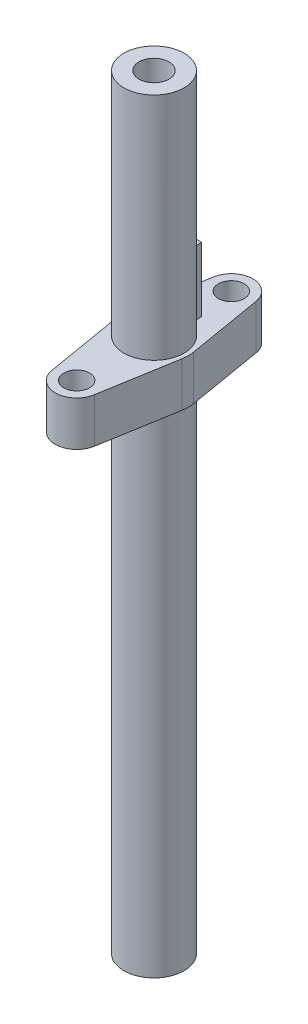
from build123d import *

# Parameters (mm, degrees)
SKETCH1_R           = 3.5
BOSS_EXTRUDE1_DEPTH = 87.927
SKETCH2_R           = 1.75
CUT_EXTRUDE1_DEPTH  = 8.9
CUT_EXTRUDE2_START  = -87.927
SKETCH2_2_R         = 1.75
CUT_EXTRUDE2_DEPTH  = 8.9
CUT_EXTRUDE3_REACH  = 9
SKETCH3_R           = 1.75
BOSS_EXTRUDE2_DEPTH = 7.5
SKETCH5_R           = 1.5
SKETCH5_R_2         = 3.5
BOSS_EXTRUDE3_DEPTH = 5.2
SKETCH6_R           = 3.5
SKETCH6_R_2         = 1.75
BOSS_EXTRUDE5_DEPTH = 1.1
SKETCH7_R           = 1.75
BOSS_EXTRUDE6_DEPTH = 0.4
SKETCH8_R           = 1.75
BOSS_EXTRUDE7_DEPTH = 1.473


with BuildPart() as part:
    # Sketch1 → Boss-Extrude1 (new body)
    with BuildSketch(Plane(origin=(0, 0, 0), x_dir=(1, 0, 0), z_dir=(0, 1, 0))):
        Circle(SKETCH1_R)
    extrude(amount=BOSS_EXTRUDE1_DEPTH)

    # Sketch2 → Cut-Extrude1 (cut)
    with BuildSketch(Plane.XZ):
        Circle(SKETCH2_R)
    extrude(amount=-CUT_EXTRUDE1_DEPTH, mode=Mode.SUBTRACT)

    # Sketch2_2 → Cut-Extrude2 (cut)
    with BuildSketch(Plane.XZ.offset(CUT_EXTRUDE2_START)):
        Circle(SKETCH2_2_R)
    extrude(amount=CUT_EXTRUDE2_DEPTH, mode=Mode.SUBTRACT)

    # Sketch3 → Cut-Extrude3 (cut, up to next)
    with BuildSketch(Plane.ZY.offset(3.5), mode=Mode.PRIVATE) as cut_extrude3_sk1:
        with Locations((0, 4.677)):
            Circle(SKETCH3_R)
    cut_extrude3_tool1 = extrude(cut_extrude3_sk1.sketch, amount=-CUT_EXTRUDE3_REACH, mode=Mode.PRIVATE) & part.part
    add(cut_extrude3_tool1.solids().sort_by_distance((-3.5, 4.677, 0))[0], mode=Mode.SUBTRACT)
    # Sketch3 → Cut-Extrude3 (cut, up to next)
    with BuildSketch(Plane.ZY.offset(3.5), mode=Mode.PRIVATE) as cut_extrude3_sk2:
        with Locations((0, 82.177)):
            Circle(SKETCH3_R)
    cut_extrude3_tool2 = extrude(cut_extrude3_sk2.sketch, amount=-CUT_EXTRUDE3_REACH, mode=Mode.PRIVATE) & part.part
    add(cut_extrude3_tool2.solids().sort_by_distance((-3.5, 82.177, 0))[0], mode=Mode.SUBTRACT)

    # Sketch4 → Boss-Extrude2 (add)
    with BuildSketch(Plane(origin=(0, 68.677, 0), x_dir=(1, 0, 0), z_dir=(0, 1, 0))):
        with BuildLine():
            Line((0.85, 3.240370349), (0.85, 4.704101966))
            Line((0.85, 4.704101966), (-0.85, 4.704101966))
            Line((-0.85, 4.704101966), (-0.85, 3.240370349))
            ThreePointArc((-0.85, 3.240370349), (0, -3.35), (0.85, 3.240370349))
        make_face()
    extrude(amount=-BOSS_EXTRUDE2_DEPTH)

    # Sketch5 → Boss-Extrude3 (add)
    with BuildSketch(Plane.XZ.offset(-61.177)):
        with BuildLine():
            Line((-3.944053189, 0.666666667), (-2.465033243, 9.416666667))
            ThreePointArc((-2.465033243, 9.416666667), (0, 11.5), (2.465033243, 9.416666667))
            Line((2.465033243, 9.416666667), (3.944053189, 0.666666667))
            ThreePointArc((3.944053189, 0.666666667), (4, 0), (3.944053189, -0.666666667))
            Line((3.944053189, -0.666666667), (2.465033243, -9.416666667))
            ThreePointArc((2.465033243, -9.416666667), (0, -11.5), (-2.465033243, -9.416666667))
            Line((-2.465033243, -9.416666667), (-3.944053189, -0.666666667))
            ThreePointArc((-3.944053189, -0.666666667), (-4, 0), (-3.944053189, 0.666666667))
        make_face()
        with Locations((0, 9)):
            Circle(SKETCH5_R, mode=Mode.SUBTRACT)
        Circle(SKETCH5_R_2, mode=Mode.SUBTRACT)
        with Locations((0, -9)):
            Circle(SKETCH5_R, mode=Mode.SUBTRACT)
    extrude(amount=BOSS_EXTRUDE3_DEPTH)

    # Sketch6 → Boss-Extrude5 (add)
    with BuildSketch(Plane(origin=(0, 0, 0), x_dir=(1, 0, 0), z_dir=(0, 1, 0))):
        Circle(SKETCH6_R)
        Circle(SKETCH6_R_2, mode=Mode.SUBTRACT)
    extrude(amount=-BOSS_EXTRUDE5_DEPTH)

    # Sketch7 → Boss-Extrude6 (add)
    with BuildSketch(Plane(origin=(0, 79.027, 0), x_dir=(1, 0, 0), z_dir=(0, 1, 0))):
        Circle(SKETCH7_R)
    extrude(amount=BOSS_EXTRUDE6_DEPTH)

    # Sketch8 → Boss-Extrude7 (add)
    with BuildSketch(Plane.XZ.offset(-8.9)):
        Circle(SKETCH8_R)
    extrude(amount=BOSS_EXTRUDE7_DEPTH)


solid = part.part
